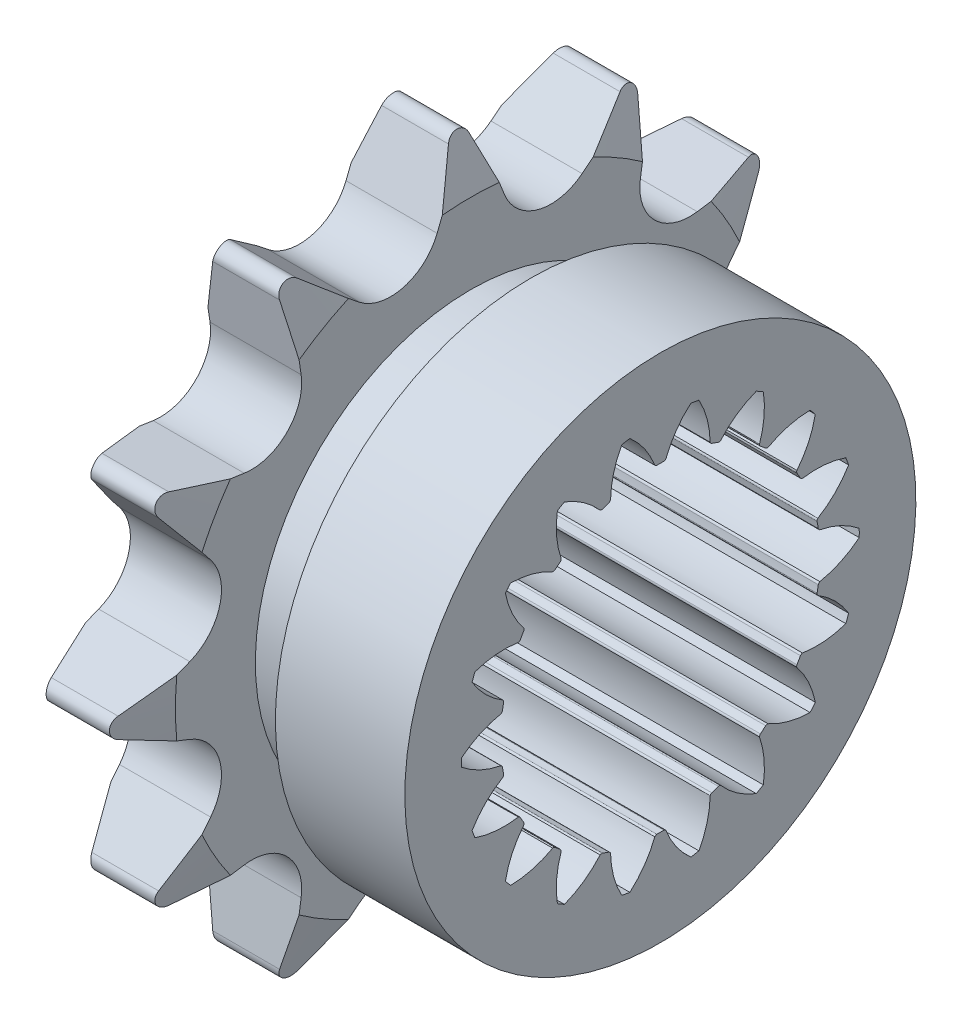
from build123d import *

# Parameters (mm, degrees)
SKETCH13_W         = 22.225
SKETCH13_H         = 27.5082
CUT_EXTRUDE1_DEPTH = 7.2136
CIRPATTERN1_COUNT  = 12
SKETCH15_W         = 127
SKETCH15_H         = 22.5171
SKETCH16_W         = 4.7625
SKETCH16_H         = 3.175
CUT_EXTRUDE2_DEPTH = 23.225


with BuildPart() as part:
    # Sketch13 → Revolve1 (revolve)
    with BuildSketch(Plane.XY):
        with Locations((11.1125, 13.7541)):
            Rectangle(SKETCH13_W, SKETCH13_H)
    revolve(axis=Axis((0, 0, 0), (-1, 0, 0)))

    # Sketch6 → Cut-Extrude1 (cut)
    with BuildSketch(Plane(origin=(0, -16.51, 0), x_dir=(0, 0, -1), z_dir=(1, 0, 0))):
        with BuildLine():
            Line((-0.805715716, 43.469749783), (-2.663822441, 38.756002806))
            ThreePointArc((-2.663822441, 38.756002806), (-5.324614334, 36.381731224), (-8.816063498, 37.107514783))
            Line((-8.816063498, 37.107514783), (-12.782104613, 40.260686049))
            ThreePointArc((-12.782104613, 40.260686049), (-13.256994885, 40.44645554), (-13.7541, 40.332800012))
            ThreePointArc((-13.7541, 40.332800012), (-7.119646056, 43.080880815), (0, 44.0182))
            ThreePointArc((0, 44.0182), (-0.487333422, 43.868076017), (-0.805715716, 43.469749783))
        make_face()
    cut_extrude1 = extrude(amount=CUT_EXTRUDE1_DEPTH, mode=Mode.SUBTRACT)

    # CirPattern1: Cut-Extrude1 ×12 about axis
    cirpattern1_axis = Axis((0, 0, 0), (1, 0, 0))
    for i in range(1, CIRPATTERN1_COUNT):
        add(cut_extrude1.rotate(cirpattern1_axis, i * 360 / CIRPATTERN1_COUNT), mode=Mode.SUBTRACT)

    # Sketch15 → hub Cut-Revolve3 (revolve, cut)
    with BuildSketch(Plane.XY):
        with Locations((70.7136, 31.48965)):
            Rectangle(SKETCH15_W, SKETCH15_H)
        with Locations((-63.5, 31.48965)):
            Rectangle(SKETCH15_W, SKETCH15_H)
    revolve(axis=Axis((0, 0, 0), (-1, 0, 0)), mode=Mode.SUBTRACT)

    # Sketch4 → Teeth Chamfer (revolve, cut)
    with BuildSketch(Plane.XY):
        Polygon((0, 27.5082), (1.104501883, 27.5082), (0, 23.386142857), align=None)
        Polygon((7.2136, 27.5082), (6.109098117, 27.5082), (7.2136, 23.386142857), align=None)
    revolve(axis=Axis((0, 0, 0), (-1, 0, 0)), mode=Mode.SUBTRACT)

    # Sketch16 → Recess (revolve, cut)
    with BuildSketch(Plane.XY):
        with Locations((9.59485, 18.6436)):
            Rectangle(SKETCH16_W, SKETCH16_H)
    revolve(axis=Axis((0, 0, 0), (-1, 0, 0)), mode=Mode.SUBTRACT)

    # Sketch36 → Cut-Extrude2 (cut, through all)
    with BuildSketch(Plane.ZY):
        with BuildLine():
            ThreePointArc((-4.7729934, 11.8201419), (-6.061029895, 12.982143528), (-7.592553624, 13.796834183))
            ThreePointArc((-7.592553624, 13.796834183), (-7.873999984, 13.638168068), (-8.152132052, 13.473761428))
            ThreePointArc((-8.152132052, 13.473761428), (-8.212351117, 11.740077645), (-7.850046439, 10.043604504))
            ThreePointArc((-7.850046439, 10.043604504), (-7.86626214, 9.947703548), (-7.918307228, 9.865537551))
            ThreePointArc((-7.918307228, 9.865537551), (-8.13141367, 9.690641477), (-8.340658225, 9.511142985))
            ThreePointArc((-8.340658225, 9.511142985), (-8.430613472, 9.474156555), (-8.527873304, 9.474840233))
            ThreePointArc((-8.527873304, 9.474840233), (-10.135659657, 10.126230162), (-11.853461818, 10.367976993))
            ThreePointArc((-11.853461818, 10.367976993), (-12.063667879, 10.122619291), (-12.268796147, 9.873000815))
            ThreePointArc((-12.268796147, 9.873000815), (-11.732428783, 8.223274824), (-10.811745764, 6.753027031))
            ThreePointArc((-10.811745764, 6.753027031), (-10.794183479, 6.657363513), (-10.814987438, 6.562352263))
            ThreePointArc((-10.814987438, 6.562352263), (-10.95542401, 6.325117018), (-11.090657474, 6.084877757))
            ThreePointArc((-11.090657474, 6.084877757), (-11.162537651, 6.019355375), (-11.254165829, 5.986733001))
            ThreePointArc((-11.254165829, 5.986733001), (-12.987779277, 6.048943991), (-14.684667578, 5.688588763))
            ThreePointArc((-14.684667578, 5.688588763), (-14.798279386, 5.386133234), (-14.905662359, 5.081410594))
            ThreePointArc((-14.905662359, 5.081410594), (-13.837402385, 3.714623697), (-12.469388985, 2.647934833))
            ThreePointArc((-12.469388985, 2.647934833), (-12.420166986, 2.564047187), (-12.407220551, 2.467650443))
            ThreePointArc((-12.407220551, 2.467650443), (-12.458048528, 2.196690097), (-12.50295975, 1.924686467))
            ThreePointArc((-12.50295975, 1.924686467), (-12.548095048, 1.8385311), (-12.623039862, 1.776537414))
            ThreePointArc((-12.623039862, 1.776537414), (-14.273381038, 1.242065902), (-15.744685706, 0.323072774))
            ThreePointArc((-15.744685706, 0.323072774), (-15.748, 1.8e-08), (-15.744685707, -0.323072738))
            ThreePointArc((-15.744685707, -0.323072738), (-14.273381041, -1.24206587), (-12.623039866, -1.776537385))
            ThreePointArc((-12.623039866, -1.776537385), (-12.548095052, -1.838531072), (-12.502959755, -1.924686439))
            ThreePointArc((-12.502959755, -1.924686439), (-12.458048533, -2.196690069), (-12.407220557, -2.467650415))
            ThreePointArc((-12.407220557, -2.467650415), (-12.420166992, -2.564047159), (-12.469388991, -2.647934805))
            ThreePointArc((-12.469388991, -2.647934805), (-13.837402393, -3.714623666), (-14.905662371, -5.08141056))
            ThreePointArc((-14.905662371, -5.08141056), (-14.798279398, -5.3861332), (-14.684667591, -5.68858873))
            ThreePointArc((-14.684667591, -5.68858873), (-12.987779291, -6.048943962), (-11.254165843, -5.986732975))
            ThreePointArc((-11.254165843, -5.986732975), (-11.162537665, -6.01935535), (-11.090657488, -6.084877731))
            ThreePointArc((-11.090657488, -6.084877731), (-10.955424024, -6.325116993), (-10.814987453, -6.562352239))
            ThreePointArc((-10.814987453, -6.562352239), (-10.794183495, -6.657363489), (-10.811745779, -6.753027006))
            ThreePointArc((-10.811745779, -6.753027006), (-11.732428801, -8.223274797), (-12.26879617, -9.873000787))
            ThreePointArc((-12.26879617, -9.873000787), (-12.063667902, -10.122619264), (-11.853461841, -10.367976966))
            ThreePointArc((-11.853461841, -10.367976966), (-10.13565968, -10.126230139), (-8.527873325, -9.474840214))
            ThreePointArc((-8.527873325, -9.474840214), (-8.430613493, -9.474156536), (-8.340658247, -9.511142966))
            ThreePointArc((-8.340658247, -9.511142966), (-8.131413692, -9.690641459), (-7.91830725, -9.865537533))
            ThreePointArc((-7.91830725, -9.865537533), (-7.866262163, -9.94770353), (-7.850046462, -10.043604486))
            ThreePointArc((-7.850046462, -10.043604486), (-8.212351144, -11.740077626), (-8.152132082, -13.473761409))
            ThreePointArc((-8.152132082, -13.473761409), (-7.874000016, -13.63816805), (-7.592553655, -13.796834166))
            ThreePointArc((-7.592553655, -13.796834166), (-6.061029924, -12.982143514), (-4.772993427, -11.820141889))
            ThreePointArc((-4.772993427, -11.820141889), (-4.681832912, -11.78623462), (-4.584652527, -11.79022399))
            ThreePointArc((-4.584652527, -11.79022399), (-4.326634863, -11.887331546), (-4.066562331, -11.9787934))
            ThreePointArc((-4.066562331, -11.9787934), (-3.98955352, -12.038203713), (-3.941515687, -12.122775038))
            ThreePointArc((-3.941515687, -12.122775038), (-3.701742737, -13.840853828), (-3.052200553, -15.449387554))
            ThreePointArc((-3.052200553, -15.449387554), (-2.73461152, -15.508752491), (-2.415871444, -15.561589545))
            ThreePointArc((-2.415871444, -15.561589545), (-1.255350509, -14.272218786), (-0.442420079, -12.739760006))
            ThreePointArc((-0.442420079, -12.739760006), (-0.368354185, -12.676718863), (-0.27567005, -12.647229995))
            ThreePointArc((-0.27567005, -12.647229995), (-1.4e-08, -12.65023401), (0.275670021, -12.647229995))
            ThreePointArc((0.275670021, -12.647229995), (0.368354156, -12.676718864), (0.44242005, -12.739760007))
            ThreePointArc((0.44242005, -12.739760007), (1.255350476, -14.272218789), (2.415871408, -15.561589551))
            ThreePointArc((2.415871408, -15.561589551), (2.734611484, -15.508752498), (3.052200518, -15.449387561))
            ThreePointArc((3.052200518, -15.449387561), (3.701742705, -13.840853836), (3.941515659, -12.122775047))
            ThreePointArc((3.941515659, -12.122775047), (3.989553493, -12.038203723), (4.066562304, -11.978793409))
            ThreePointArc((4.066562304, -11.978793409), (4.326634836, -11.887331556), (4.5846525, -11.790224))
            ThreePointArc((4.5846525, -11.790224), (4.681832885, -11.786234631), (4.7729934, -11.8201419))
            ThreePointArc((4.7729934, -11.8201419), (6.061029895, -12.982143528), (7.592553624, -13.796834183))
            ThreePointArc((7.592553624, -13.796834183), (7.873999984, -13.638168068), (8.152132052, -13.473761428))
            ThreePointArc((8.152132052, -13.473761428), (8.212351117, -11.740077645), (7.850046439, -10.043604504))
            ThreePointArc((7.850046439, -10.043604504), (7.86626214, -9.947703548), (7.918307228, -9.865537551))
            ThreePointArc((7.918307228, -9.865537551), (8.13141367, -9.690641477), (8.340658225, -9.511142985))
            ThreePointArc((8.340658225, -9.511142985), (8.430613472, -9.474156555), (8.527873304, -9.474840233))
            ThreePointArc((8.527873304, -9.474840233), (10.135659657, -10.126230162), (11.853461818, -10.367976993))
            ThreePointArc((11.853461818, -10.367976993), (12.063667879, -10.122619291), (12.268796147, -9.873000815))
            ThreePointArc((12.268796147, -9.873000815), (11.732428783, -8.223274824), (10.811745764, -6.753027031))
            ThreePointArc((10.811745764, -6.753027031), (10.794183479, -6.657363513), (10.814987438, -6.562352263))
            ThreePointArc((10.814987438, -6.562352263), (10.95542401, -6.325117018), (11.090657474, -6.084877757))
            ThreePointArc((11.090657474, -6.084877757), (11.162537651, -6.019355375), (11.254165829, -5.986733001))
            ThreePointArc((11.254165829, -5.986733001), (12.987779277, -6.048943991), (14.684667578, -5.688588763))
            ThreePointArc((14.684667578, -5.688588763), (14.798279386, -5.386133234), (14.905662359, -5.081410594))
            ThreePointArc((14.905662359, -5.081410594), (13.837402385, -3.714623697), (12.469388985, -2.647934833))
            ThreePointArc((12.469388985, -2.647934833), (12.420166986, -2.564047187), (12.407220551, -2.467650443))
            ThreePointArc((12.407220551, -2.467650443), (12.458048528, -2.196690097), (12.50295975, -1.924686467))
            ThreePointArc((12.50295975, -1.924686467), (12.548095048, -1.8385311), (12.623039862, -1.776537414))
            ThreePointArc((12.623039862, -1.776537414), (14.273381038, -1.242065902), (15.744685706, -0.323072774))
            ThreePointArc((15.744685706, -0.323072774), (15.748, -1.8e-08), (15.744685707, 0.323072738))
            ThreePointArc((15.744685707, 0.323072738), (14.273381041, 1.24206587), (12.623039866, 1.776537385))
            ThreePointArc((12.623039866, 1.776537385), (12.548095052, 1.838531072), (12.502959755, 1.924686439))
            ThreePointArc((12.502959755, 1.924686439), (12.458048533, 2.196690069), (12.407220557, 2.467650415))
            ThreePointArc((12.407220557, 2.467650415), (12.420166992, 2.564047159), (12.469388991, 2.647934805))
            ThreePointArc((12.469388991, 2.647934805), (13.837402393, 3.714623666), (14.905662371, 5.08141056))
            ThreePointArc((14.905662371, 5.08141056), (14.798279398, 5.3861332), (14.684667591, 5.68858873))
            ThreePointArc((14.684667591, 5.68858873), (12.987779291, 6.048943962), (11.254165843, 5.986732975))
            ThreePointArc((11.254165843, 5.986732975), (11.162537665, 6.01935535), (11.090657488, 6.084877731))
            ThreePointArc((11.090657488, 6.084877731), (10.955424024, 6.325116993), (10.814987453, 6.562352239))
            ThreePointArc((10.814987453, 6.562352239), (10.794183495, 6.657363489), (10.811745779, 6.753027006))
            ThreePointArc((10.811745779, 6.753027006), (11.732428801, 8.223274797), (12.26879617, 9.873000787))
            ThreePointArc((12.26879617, 9.873000787), (12.063667902, 10.122619264), (11.853461841, 10.367976966))
            ThreePointArc((11.853461841, 10.367976966), (10.13565968, 10.126230139), (8.527873325, 9.474840214))
            ThreePointArc((8.527873325, 9.474840214), (8.430613493, 9.474156536), (8.340658247, 9.511142966))
            ThreePointArc((8.340658247, 9.511142966), (8.131413692, 9.690641459), (7.91830725, 9.865537533))
            ThreePointArc((7.91830725, 9.865537533), (7.866262163, 9.94770353), (7.850046462, 10.043604486))
            ThreePointArc((7.850046462, 10.043604486), (8.212351144, 11.740077626), (8.152132082, 13.473761409))
            ThreePointArc((8.152132082, 13.473761409), (7.874000016, 13.63816805), (7.592553655, 13.796834166))
            ThreePointArc((7.592553655, 13.796834166), (6.061029924, 12.982143514), (4.772993427, 11.820141889))
            ThreePointArc((4.772993427, 11.820141889), (4.681832912, 11.78623462), (4.584652527, 11.79022399))
            ThreePointArc((4.584652527, 11.79022399), (4.326634863, 11.887331546), (4.066562331, 11.9787934))
            ThreePointArc((4.066562331, 11.9787934), (3.98955352, 12.038203713), (3.941515687, 12.122775038))
            ThreePointArc((3.941515687, 12.122775038), (3.701742737, 13.840853828), (3.052200553, 15.449387554))
            ThreePointArc((3.052200553, 15.449387554), (2.73461152, 15.508752491), (2.415871444, 15.561589545))
            ThreePointArc((2.415871444, 15.561589545), (1.255350509, 14.272218786), (0.442420079, 12.739760006))
            ThreePointArc((0.442420079, 12.739760006), (0.368354185, 12.676718863), (0.27567005, 12.647229995))
            ThreePointArc((0.27567005, 12.647229995), (1.4e-08, 12.65023401), (-0.275670021, 12.647229995))
            ThreePointArc((-0.275670021, 12.647229995), (-0.368354156, 12.676718864), (-0.44242005, 12.739760007))
            ThreePointArc((-0.44242005, 12.739760007), (-1.255350476, 14.272218789), (-2.415871408, 15.561589551))
            ThreePointArc((-2.415871408, 15.561589551), (-2.734611484, 15.508752498), (-3.052200518, 15.449387561))
            ThreePointArc((-3.052200518, 15.449387561), (-3.701742705, 13.840853836), (-3.941515659, 12.122775047))
            ThreePointArc((-3.941515659, 12.122775047), (-3.989553493, 12.038203723), (-4.066562304, 11.978793409))
            ThreePointArc((-4.066562304, 11.978793409), (-4.326634836, 11.887331556), (-4.5846525, 11.790224))
            ThreePointArc((-4.5846525, 11.790224), (-4.681832885, 11.786234631), (-4.7729934, 11.8201419))
        make_face()
    extrude(amount=-CUT_EXTRUDE2_DEPTH, mode=Mode.SUBTRACT)


solid = part.part
